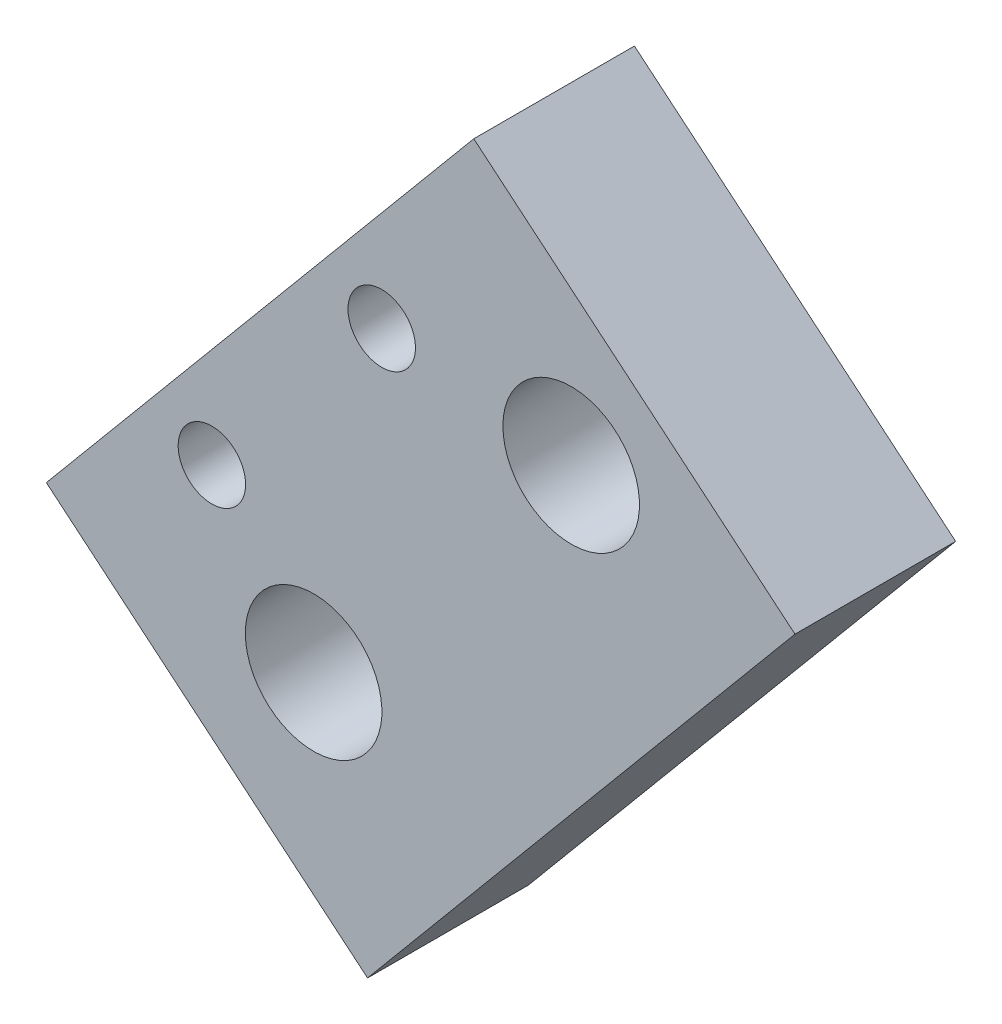
from build123d import *

# Parameters (mm, degrees)
SKETCH2_R           = 4.25
SKETCH2_R_2         = 2.1
BOSS_EXTRUDE1_DEPTH = 10


with BuildPart() as part:
    # Sketch2 → Boss-Extrude1 (new body)
    with BuildSketch(Plane(origin=(0, 0, 3306.870187265), x_dir=(-1, 0, 0), z_dir=(0, 0, -1))):
        Polygon((-107.287132076, 528.630767378), (-87.295661635, 545.336840216), (-60.692285166, 513.501673478), (-80.683755608, 496.79560064), align=None)
        with Locations((-77.326966288, 511.582577545)):
            Circle(SKETCH2_R, mode=Mode.SUBTRACT)
        with Locations((-93.357902826, 530.766140137)):
            Circle(SKETCH2_R, mode=Mode.SUBTRACT)
        with Locations((-81.566936891, 532.251222865)):
            Circle(SKETCH2_R_2, mode=Mode.SUBTRACT)
        with Locations((-70.99449696, 519.599618719)):
            Circle(SKETCH2_R_2, mode=Mode.SUBTRACT)
    extrude(amount=BOSS_EXTRUDE1_DEPTH)


solid = part.part
